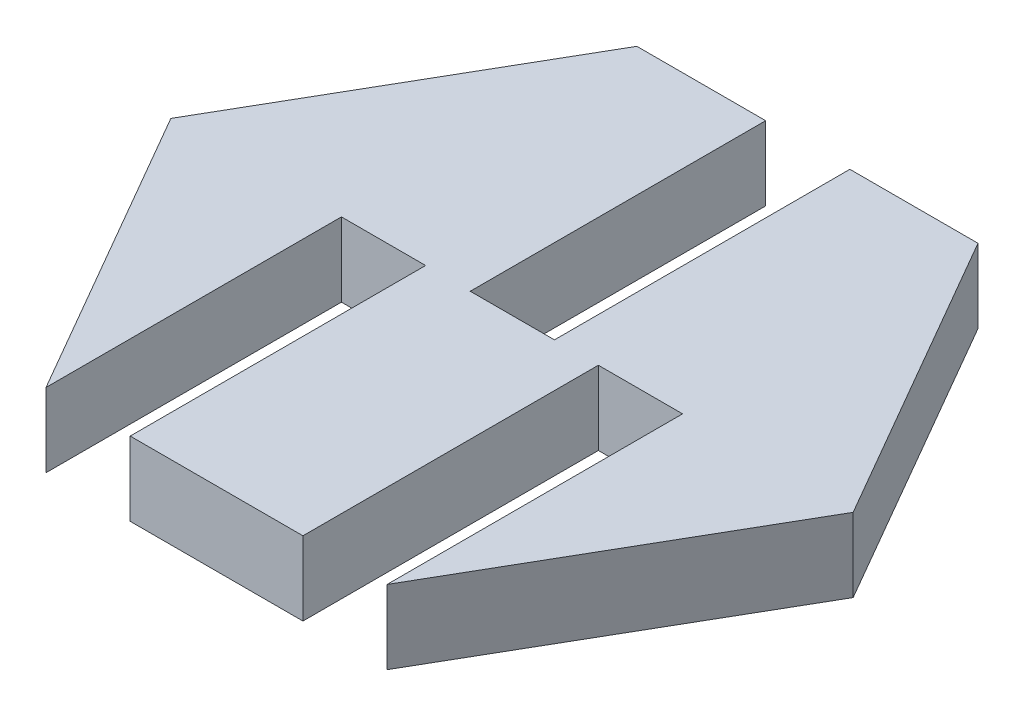
from build123d import *

# Parameters (mm, degrees)
BOSS_EXTRUDE1_DEPTH = 2.5
SKETCH5_W           = 2.85
SKETCH5_H           = 2.5
CUT_EXTRUDE3_DEPTH  = 10
SKETCH6_W           = 2.85
SKETCH6_H           = 2.5
CUT_EXTRUDE4_DEPTH  = 10
SKETCH7_W           = 2.85
SKETCH7_H           = 2.5
CUT_EXTRUDE5_DEPTH  = 10


with BuildPart() as part:
    # Sketch1 → Boss-Extrude1 (new body)
    with BuildSketch(Plane(origin=(0, 0, 0), x_dir=(1, 0, 0), z_dir=(0, 1, 0))):
        Polygon((11.547005384, 0), (5.773502692, 10), (-5.773502692, 10), (-11.547005384, 0), (-5.773502692, -10), (5.773502692, -10), align=None)
    extrude(amount=BOSS_EXTRUDE1_DEPTH)

    # Sketch5 → Cut-Extrude3 (cut)
    with BuildSketch(Plane.XY.offset(10)):
        with Locations((-4.348502692, 1.25)):
            Rectangle(SKETCH5_W, SKETCH5_H)
    extrude(amount=-CUT_EXTRUDE3_DEPTH, mode=Mode.SUBTRACT)

    # Sketch6 → Cut-Extrude4 (cut)
    with BuildSketch(Plane.XY.offset(10)):
        with Locations((4.348502692, 1.25)):
            Rectangle(SKETCH6_W, SKETCH6_H)
    extrude(amount=-CUT_EXTRUDE4_DEPTH, mode=Mode.SUBTRACT)

    # Sketch7 → Cut-Extrude5 (cut)
    with BuildSketch(Plane(origin=(0, 0, -10), x_dir=(-1, 0, 0), z_dir=(0, 0, -1))):
        with Locations((-0.011497308, 1.25)):
            Rectangle(SKETCH7_W, SKETCH7_H)
    extrude(amount=-CUT_EXTRUDE5_DEPTH, mode=Mode.SUBTRACT)


solid = part.part
